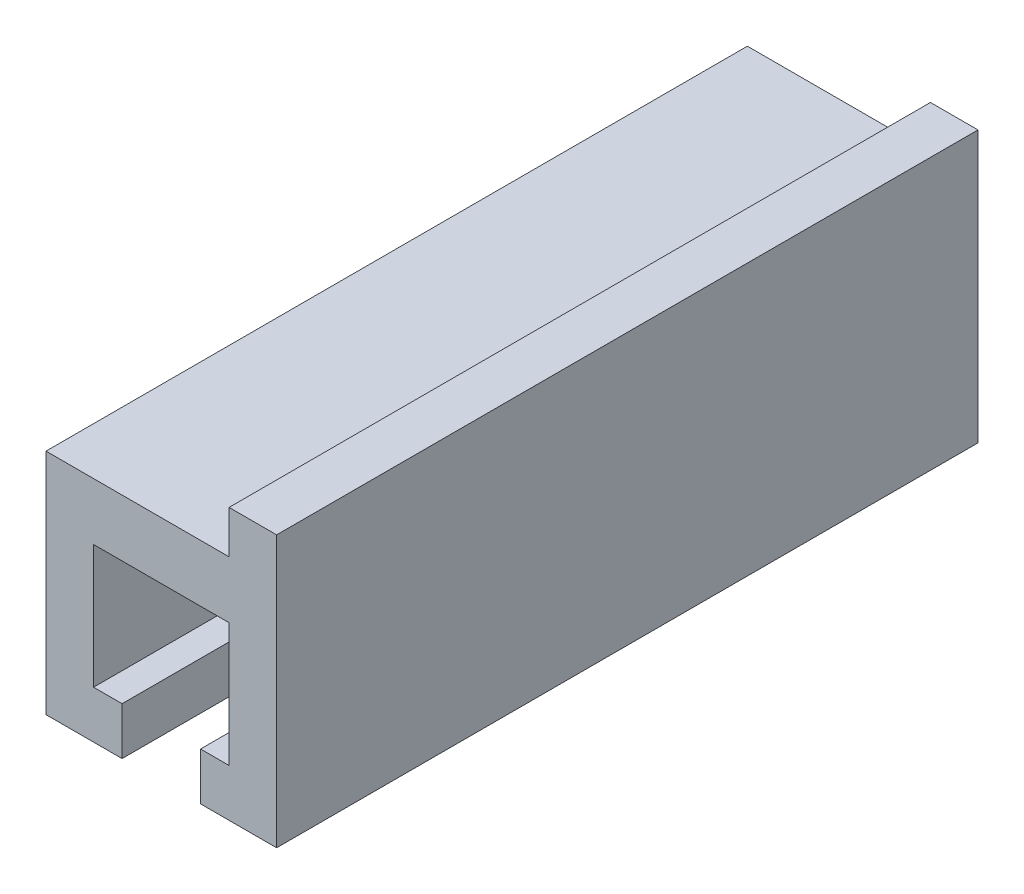
from build123d import *

# Parameters (mm, degrees)
BOSS_EXTRUDE1_DEPTH = 29.5
SKETCH2_W           = 2
SKETCH2_H           = 1.8
BOSS_EXTRUDE2_DEPTH = 29.5


with BuildPart() as part:
    # Sketch1 → Boss-Extrude1 (new body)
    with BuildSketch(Plane.XY):
        Polygon((-7.65, 2.6), (2.05, 2.6), (2.05, -7), (-1.15, -7), (-1.15, -5), (0.05, -5), (0.05, 0.2), (-5.65, 0.2), (-5.65, -5), (-4.45, -5), (-4.45, -7), (-7.65, -7), align=None)
    extrude(amount=BOSS_EXTRUDE1_DEPTH)

    # Sketch2 → Boss-Extrude2 (add)
    with BuildSketch(Plane.XY.offset(29.5)):
        with Locations((1.05, 3.5)):
            Rectangle(SKETCH2_W, SKETCH2_H)
    extrude(amount=-BOSS_EXTRUDE2_DEPTH)


solid = part.part
